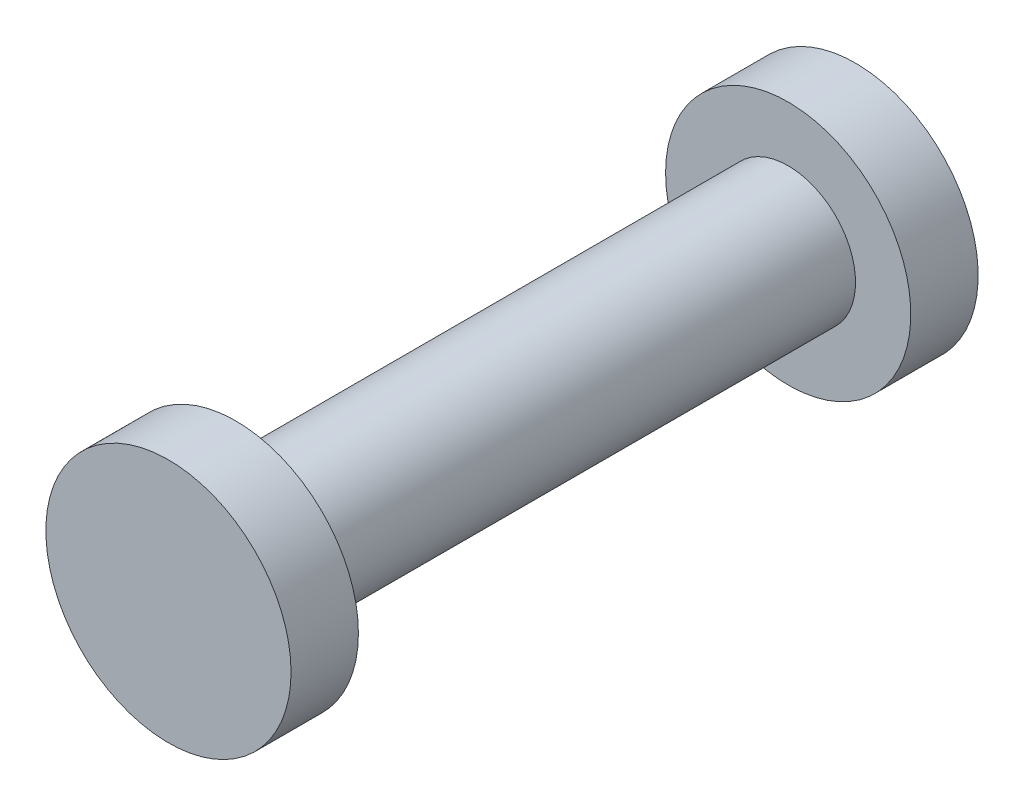
from build123d import *

# Parameters (mm, degrees)
SKETCH1_R           = 0.5
BOSS_EXTRUDE1_DEPTH = 5.1
SKETCH2_R           = 0.91
BOSS_EXTRUDE2_DEPTH = 0.5
SKETCH3_R           = 0.91
BOSS_EXTRUDE3_DEPTH = 0.5


with BuildPart() as part:
    # Sketch1 → Boss-Extrude1 (new body)
    with BuildSketch(Plane.XY):
        Circle(SKETCH1_R)
    extrude(amount=BOSS_EXTRUDE1_DEPTH)

    # Sketch2 → Boss-Extrude2 (add)
    with BuildSketch(Plane.XY.offset(5.1)):
        Circle(SKETCH2_R)
    extrude(amount=-BOSS_EXTRUDE2_DEPTH)

    # Sketch3 → Boss-Extrude3 (add)
    with BuildSketch(Plane(origin=(0, 0, 0), x_dir=(-1, 0, 0), z_dir=(0, 0, -1))):
        Circle(SKETCH3_R)
    extrude(amount=-BOSS_EXTRUDE3_DEPTH)


solid = part.part
